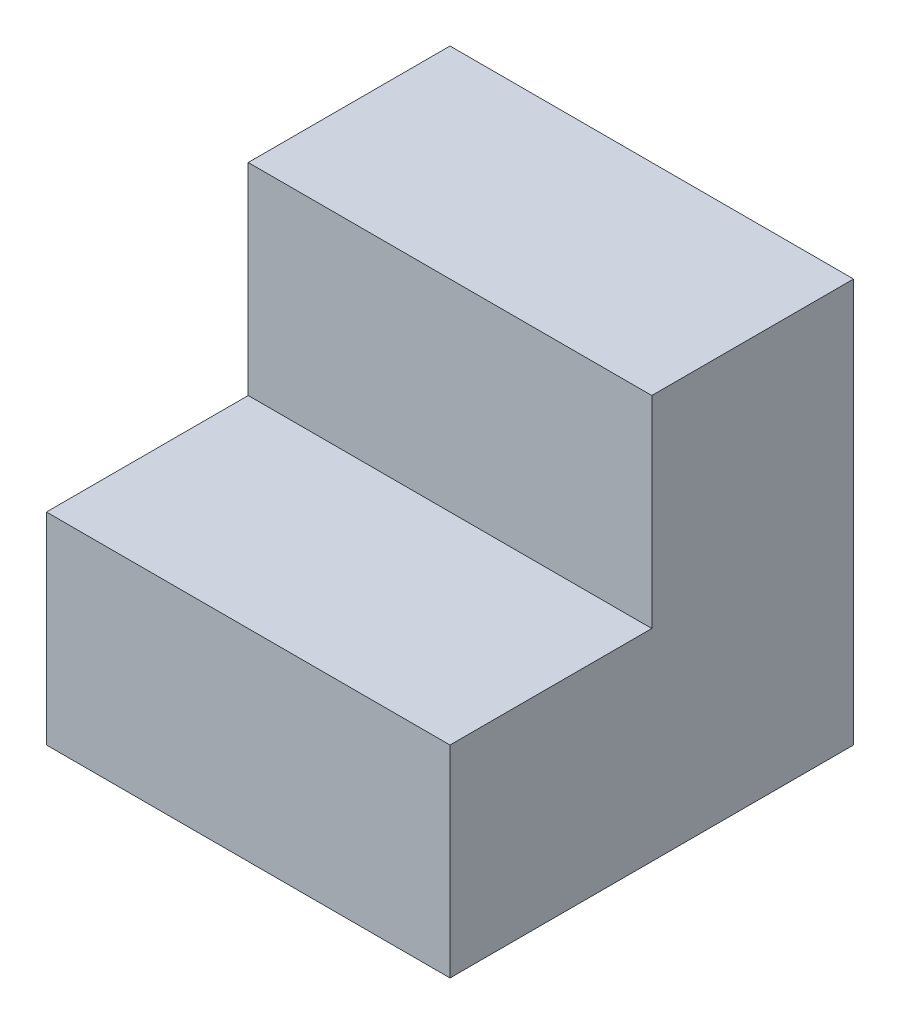
from build123d import *

# Parameters (mm, degrees)
BOSS_EXTRUDE1_DEPTH = 15


with BuildPart() as part:
    # Sketch1 → Boss-Extrude1 (new body, symmetric)
    with BuildSketch(Plane(origin=(0, 0, 0), x_dir=(0, 0, -1), z_dir=(1, 0, 0))):
        Polygon((0, 0), (0, 30), (-15, 30), (-15, 15), (-30, 15), (-30, 0), align=None)
    extrude(amount=BOSS_EXTRUDE1_DEPTH, both=True)


solid = part.part
